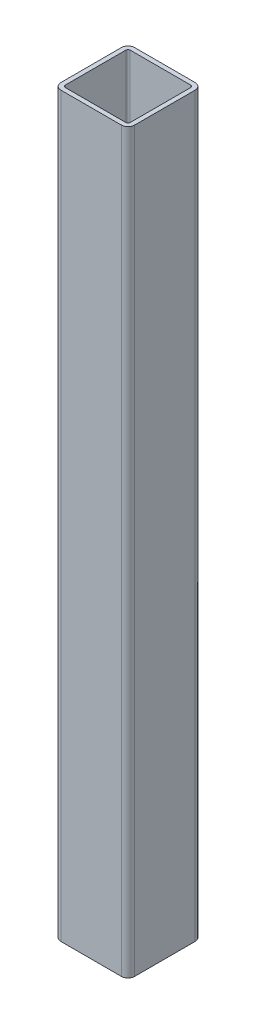
from build123d import *

# Parameters (mm, degrees)
PTR_ASTM_A500_GRADO_B_1_DEPTH = 500


with BuildPart() as part:
    # Sketch11 → Ptr ASTM A500 GRADO B(1) (new body)
    with BuildSketch(Plane(origin=(0, 0, 0), x_dir=(-1, 0, 0), z_dir=(0, 1, 0))):
        with BuildLine():
            Line((20.5, 25), (-20.5, 25))
            ThreePointArc((-20.5, 25), (-23.681980515, 23.681980515), (-25, 20.5))
            Line((-25, 20.5), (-25, -20.5))
            ThreePointArc((-25, -20.5), (-23.681980515, -23.681980515), (-20.5, -25))
            Line((-20.5, -25), (20.5, -25))
            ThreePointArc((20.5, -25), (23.681980515, -23.681980515), (25, -20.5))
            Line((25, -20.5), (25, 20.5))
            ThreePointArc((25, 20.5), (23.681980515, 23.681980515), (20.5, 25))
        make_face()
        with BuildLine():
            Line((20.5, 22), (-20.5, 22))
            ThreePointArc((-20.5, 22), (-21.560660172, 21.560660172), (-22, 20.5))
            Line((-22, 20.5), (-22, -20.5))
            ThreePointArc((-22, -20.5), (-21.560660172, -21.560660172), (-20.5, -22))
            Line((-20.5, -22), (20.5, -22))
            ThreePointArc((20.5, -22), (21.560660172, -21.560660172), (22, -20.5))
            Line((22, -20.5), (22, 20.5))
            ThreePointArc((22, 20.5), (21.560660172, 21.560660172), (20.5, 22))
        make_face(mode=Mode.SUBTRACT)
    extrude(amount=PTR_ASTM_A500_GRADO_B_1_DEPTH)


solid = part.part
